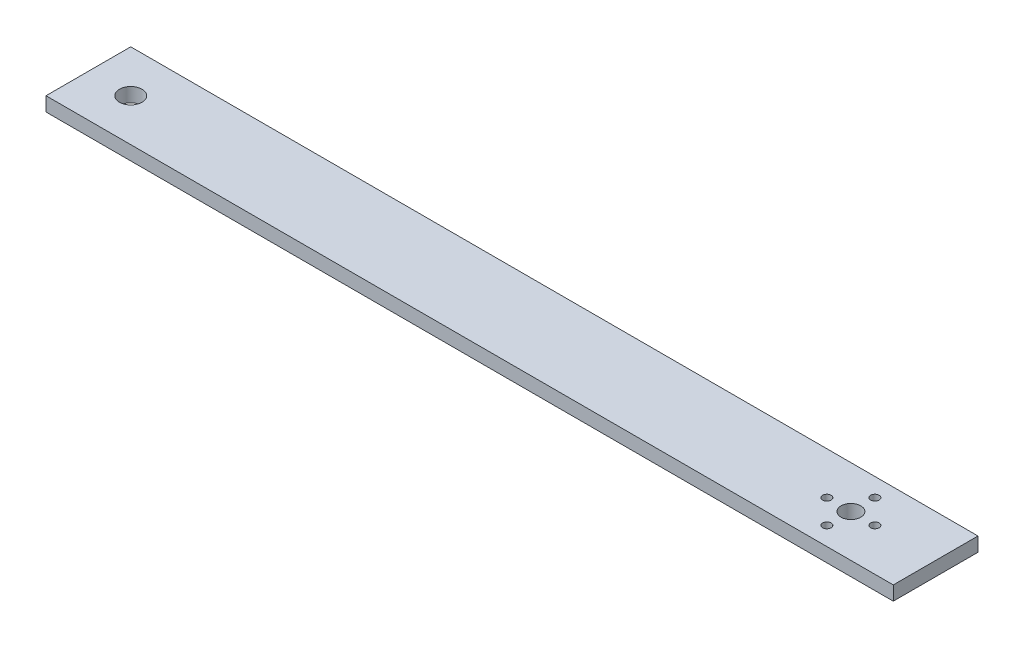
from build123d import *

# Parameters (mm, degrees)
SKETCH1_W           = 300
SKETCH1_H           = 30
SKETCH1_R           = 4
SKETCH1_R_2         = 3.5
SKETCH1_R_3         = 1.5
BOSS_EXTRUDE1_DEPTH = 5


with BuildPart() as part:
    # Sketch1 → Boss-Extrude1 (new body)
    with BuildSketch(Plane(origin=(0, 0, 0), x_dir=(1, 0, 0), z_dir=(0, 1, 0))):
        with Locations((150, 15)):
            Rectangle(SKETCH1_W, SKETCH1_H)
        with Locations((15, 15)):
            Circle(SKETCH1_R, mode=Mode.SUBTRACT)
        with Locations((270, 15)):
            Circle(SKETCH1_R_2, mode=Mode.SUBTRACT)
        with Locations((278.5, 15)):
            Circle(SKETCH1_R_3, mode=Mode.SUBTRACT)
        with Locations((261.5, 15)):
            Circle(SKETCH1_R_3, mode=Mode.SUBTRACT)
        with Locations((270, 23.5)):
            Circle(SKETCH1_R_3, mode=Mode.SUBTRACT)
        with Locations((270, 6.5)):
            Circle(SKETCH1_R_3, mode=Mode.SUBTRACT)
    extrude(amount=BOSS_EXTRUDE1_DEPTH)


solid = part.part
